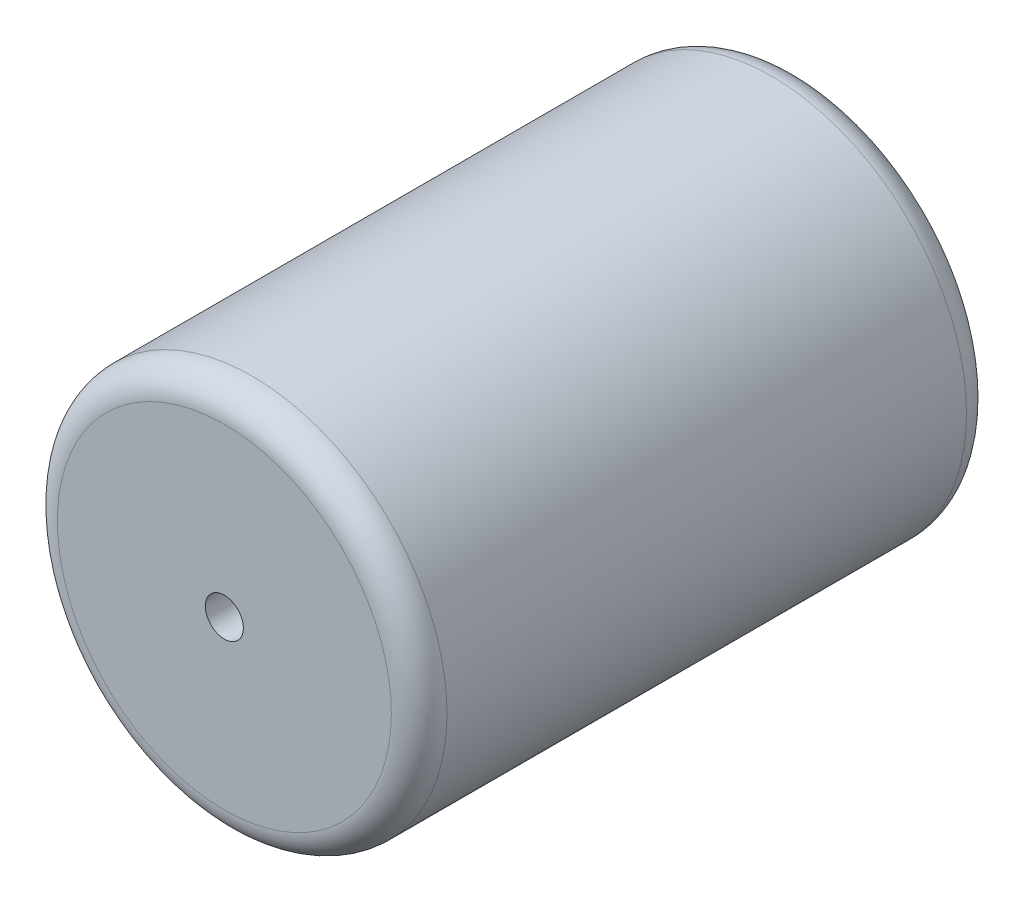
from build123d import *

# Parameters (mm, degrees)
SKETCH1_R           = 10.5
BOSS_EXTRUDE1_DEPTH = 31
FILLET1_R           = 1.5
SKETCH2_R           = 1.025
CUT_EXTRUDE1_DEPTH  = 35


with BuildPart() as part:
    # Sketch1 → Boss-Extrude1 (new body)
    with BuildSketch(Plane.XY):
        Circle(SKETCH1_R)
    extrude(amount=BOSS_EXTRUDE1_DEPTH)

    # Fillet1
    fillet1_edges = [part.edges().sort_by_distance(p)[0] for p in [
        (-10.5, 0, 0),
        (-10.5, 0, 31),
    ]]
    fillet(fillet1_edges, radius=FILLET1_R)

    # Sketch2 → Cut-Extrude1 (cut)
    with BuildSketch(Plane(origin=(0, 0, 0), x_dir=(-1, 0, 0), z_dir=(0, 0, -1))):
        Circle(SKETCH2_R)
    extrude(amount=-CUT_EXTRUDE1_DEPTH, mode=Mode.SUBTRACT)


solid = part.part
